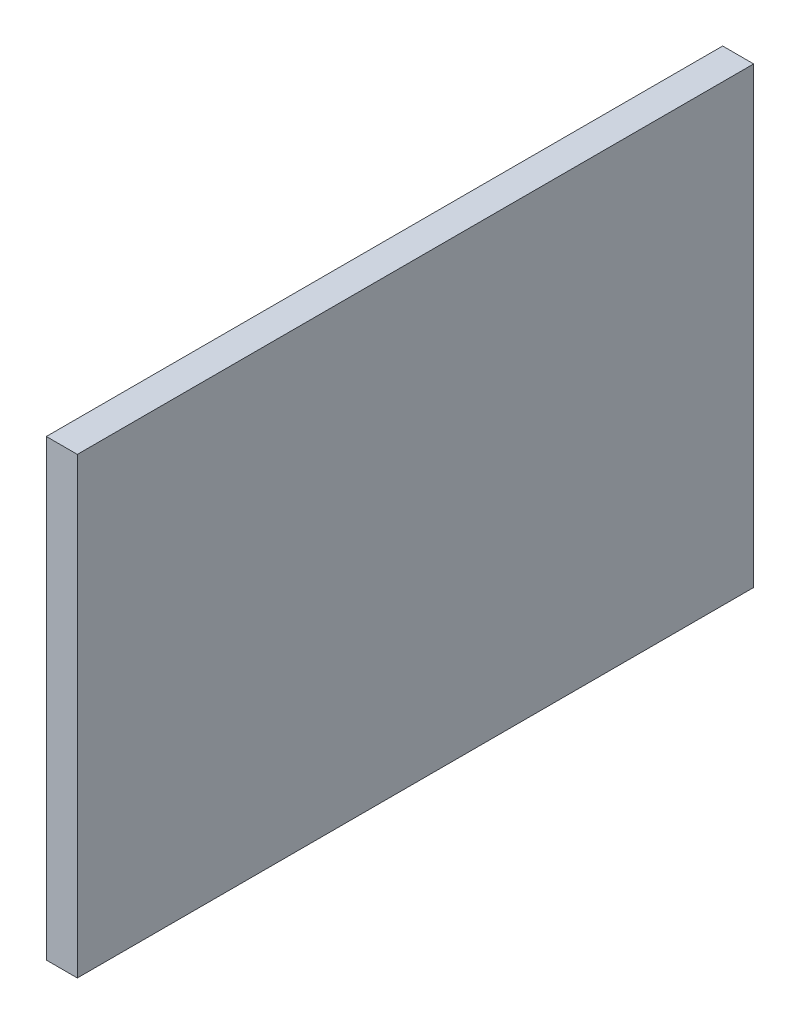
from build123d import *

# Parameters (mm, degrees)
SKETCH1_W           = 23.4
SKETCH1_H           = 34.9
BOSS_EXTRUDE1_DEPTH = 1.6


with BuildPart() as part:
    # Sketch1 → Boss-Extrude1 (new body)
    with BuildSketch(Plane.YZ):
        with Locations((57.87, 107.93)):
            Rectangle(SKETCH1_W, SKETCH1_H)
    extrude(amount=BOSS_EXTRUDE1_DEPTH)


solid = part.part
